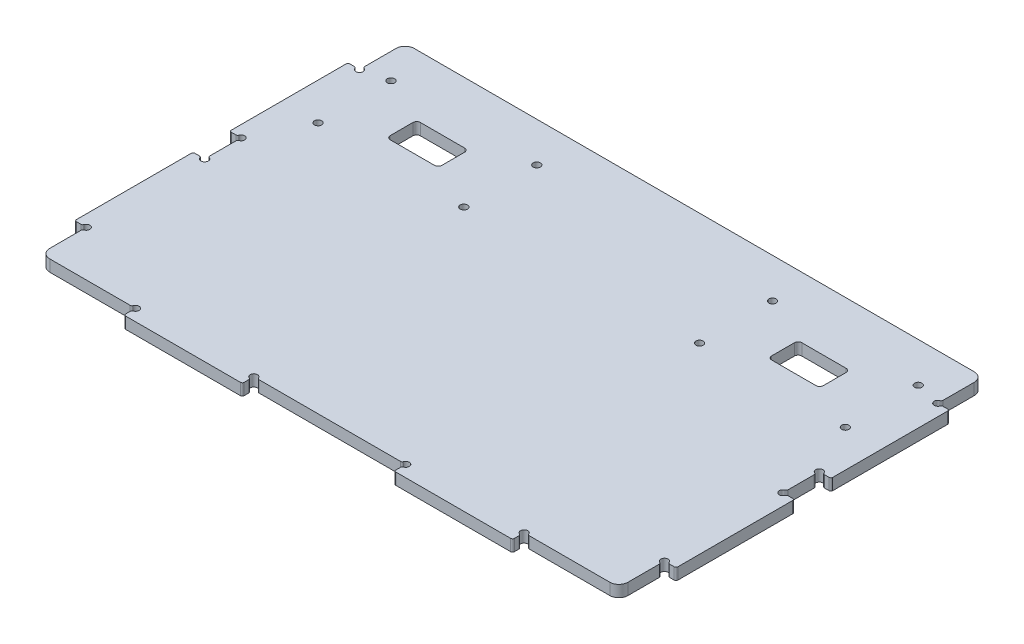
from build123d import *

# Parameters (mm, degrees)
SKETCH1_W              = 317.3
SKETCH1_H              = 363.32
BOSS_EXTRUDE1_DEPTH    = 6.35
SKETCH11_W             = 28.32
SKETCH11_H             = 16.5
CUT_EXTRUDE8_DEPTH     = 7.35
SKETCH12_R             = 2
CUT_EXTRUDE9_DEPTH     = 7.35
FILLET4_R              = 2
SKETCH14_W             = 317.3
SKETCH14_H             = 163.32
CUT_EXTRUDE10_DEPTH    = 6.35
SKETCH15_W             = 6.35
SKETCH15_H             = 65
BOSS_EXTRUDE2_DEPTH    = 6.35
SKETCH16_R             = 2
CUT_EXTRUDE11_DEPTH    = 6.35
FILLET5_R              = 1
LPATTERN1_COUNT        = 2
LPATTERN1_PITCH        = 85
FILLET5_OF_LPATTERN1_R = 1
FILLET6_R              = 5
SKETCH18_W             = 6.35
SKETCH18_H             = 65
BOSS_EXTRUDE3_DEPTH    = 6.35
SKETCH19_R             = 2
CUT_EXTRUDE12_DEPTH    = 6.35
FILLET7_R              = 1
LPATTERN2_COUNT        = 2
LPATTERN2_PITCH        = 85
FILLET7_OF_LPATTERN2_R = 1
SKETCH20_W             = 65
SKETCH20_H             = 6.35
BOSS_EXTRUDE4_DEPTH    = 6.35
SKETCH21_R             = 2
CUT_EXTRUDE13_DEPTH    = 6.35
FILLET8_R              = 1
FILLET8_OF_MIRROR10_R  = 1


with BuildPart() as part:
    # Sketch1 → Boss-Extrude1 (new body)
    with BuildSketch(Plane(origin=(0, 0, 0), x_dir=(1, 0, 0), z_dir=(0, 1, 0))):
        Rectangle(SKETCH1_W, SKETCH1_H)
    extrude(amount=-BOSS_EXTRUDE1_DEPTH)

    # Sketch11 → Cut-Extrude8 (cut, through all)
    with BuildSketch(Plane(origin=(0, 0, 0), x_dir=(1, 0, 0), z_dir=(0, 1, 0))):
        with Locations((104.666666667, -23.41)):
            Rectangle(SKETCH11_W, SKETCH11_H)
    cut_extrude8 = extrude(amount=-CUT_EXTRUDE8_DEPTH, mode=Mode.SUBTRACT)

    # Sketch12 → Cut-Extrude9 (cut, through all)
    with BuildSketch(Plane(origin=(0, 0, 0), x_dir=(1, 0, 0), z_dir=(0, 1, 0))):
        with Locations((64.666666667, -3.41)):
            Circle(SKETCH12_R)
        with Locations((144.666666667, -3.41)):
            Circle(SKETCH12_R)
        with Locations((144.666666667, -43.41)):
            Circle(SKETCH12_R)
        with Locations((64.666666667, -43.41)):
            Circle(SKETCH12_R)
    cut_extrude9 = extrude(amount=-CUT_EXTRUDE9_DEPTH, mode=Mode.SUBTRACT)

    # Mirror3: Cut-Extrude8, Cut-Extrude9 across plane
    add(cut_extrude8.mirror(Plane(origin=(0, 0, 0), x_dir=(0, 0, 1), z_dir=(1, 0, 0))), mode=Mode.SUBTRACT)
    add(cut_extrude9.mirror(Plane(origin=(0, 0, 0), x_dir=(0, 0, 1), z_dir=(1, 0, 0))), mode=Mode.SUBTRACT)

    # Fillet4
    fillet4_edges = [part.edges().sort_by_distance(p)[0] for p in [
        (90.506666667, -3.175, 31.66),
        (90.506666667, -3.175, 15.16),
        (118.826666667, -3.175, 15.16),
        (118.826666667, -3.175, 31.66),
        (-90.506666667, -3.175, 15.16),
        (-90.506666667, -3.175, 31.66),
        (-118.826666667, -3.175, 31.66),
        (-118.826666667, -3.175, 15.16),
    ]]
    fillet(fillet4_edges, radius=FILLET4_R)

    # Sketch14 → Cut-Extrude10 (cut)
    with BuildSketch(Plane(origin=(0, 0, 0), x_dir=(1, 0, 0), z_dir=(0, 1, 0))):
        with Locations((0, 100)):
            Rectangle(SKETCH14_W, SKETCH14_H)
    extrude(amount=-CUT_EXTRUDE10_DEPTH, mode=Mode.SUBTRACT)

    # Sketch15 → Boss-Extrude2 (add)
    with BuildSketch(Plane(origin=(0, 0, 0), x_dir=(1, 0, 0), z_dir=(0, 1, 0))):
        with Locations((161.825, -39.16)):
            Rectangle(SKETCH15_W, SKETCH15_H)
    boss_extrude2 = extrude(amount=-BOSS_EXTRUDE2_DEPTH)

    # Sketch16 → Cut-Extrude11 (cut)
    with BuildSketch(Plane(origin=(0, 0, 0), x_dir=(1, 0, 0), z_dir=(0, 1, 0))):
        with Locations((158.65, -71.66)):
            Circle(SKETCH16_R)
        with Locations((158.65, -6.66)):
            Circle(SKETCH16_R)
    cut_extrude11 = extrude(amount=-CUT_EXTRUDE11_DEPTH, mode=Mode.SUBTRACT)

    # Fillet5
    fillet5_edges = [part.edges().sort_by_distance(p)[0] for p in [
        (165, -3.175, 6.66),
        (165, -3.175, 71.66),
        (160.65, -3.175, 71.66),
        (160.65, -3.175, 6.66),
        (158.65, -3.175, 73.66),
        (158.65, -3.175, 4.66),
    ]]
    fillet(fillet5_edges, radius=FILLET5_R)

    # LPattern1: Boss-Extrude2, Cut-Extrude11 ×2
    with Locations(*[(0, 0, i * LPATTERN1_PITCH) for i in range(1, LPATTERN1_COUNT)]):
        add(boss_extrude2)
        add(cut_extrude11, mode=Mode.SUBTRACT)

    # Fillet5 of LPattern1
    fillet5_of_lpattern1_edges = [part.edges().sort_by_distance(p)[0] for p in [
        (165, -3.175, 91.66),
        (165, -3.175, 156.66),
        (160.65, -3.175, 156.66),
        (160.65, -3.175, 91.66),
        (158.65, -3.175, 158.66),
        (158.65, -3.175, 89.66),
    ]]
    fillet(fillet5_of_lpattern1_edges, radius=FILLET5_OF_LPATTERN1_R)

    # Fillet6
    fillet6_edges = [part.edges().sort_by_distance(p)[0] for p in [
        (158.65, -3.175, -18.34),
        (-158.65, -3.175, -18.34),
        (158.65, -3.175, 181.66),
        (-158.65, -3.175, 181.66),
    ]]
    fillet(fillet6_edges, radius=FILLET6_R)

    # Sketch18 → Boss-Extrude3 (add)
    with BuildSketch(Plane(origin=(0, 0, 0), x_dir=(1, 0, 0), z_dir=(0, 1, 0))):
        with Locations((-161.825, -39.16)):
            Rectangle(SKETCH18_W, SKETCH18_H)
    boss_extrude3 = extrude(amount=-BOSS_EXTRUDE3_DEPTH)

    # Sketch19 → Cut-Extrude12 (cut)
    with BuildSketch(Plane(origin=(0, 0, 0), x_dir=(1, 0, 0), z_dir=(0, 1, 0))):
        with Locations((-158.65, -6.66)):
            Circle(SKETCH19_R)
        with Locations((-158.65, -71.66)):
            Circle(SKETCH19_R)
    cut_extrude12 = extrude(amount=-CUT_EXTRUDE12_DEPTH, mode=Mode.SUBTRACT)

    # Fillet7
    fillet7_edges = [part.edges().sort_by_distance(p)[0] for p in [
        (-165, -3.175, 71.66),
        (-165, -3.175, 6.66),
        (-160.65, -3.175, 6.66),
        (-160.65, -3.175, 71.66),
        (-158.65, -3.175, 4.66),
        (-158.65, -3.175, 73.66),
    ]]
    fillet(fillet7_edges, radius=FILLET7_R)

    # LPattern2: Boss-Extrude3, Cut-Extrude12 ×2
    with Locations(*[(0, 0, i * LPATTERN2_PITCH) for i in range(1, LPATTERN2_COUNT)]):
        add(boss_extrude3)
        add(cut_extrude12, mode=Mode.SUBTRACT)

    # Fillet7 of LPattern2
    fillet7_of_lpattern2_edges = [part.edges().sort_by_distance(p)[0] for p in [
        (-165, -3.175, 156.66),
        (-165, -3.175, 91.66),
        (-160.65, -3.175, 91.66),
        (-160.65, -3.175, 156.66),
        (-158.65, -3.175, 89.66),
        (-158.65, -3.175, 158.66),
    ]]
    fillet(fillet7_of_lpattern2_edges, radius=FILLET7_OF_LPATTERN2_R)

    # Sketch20 → Boss-Extrude4 (add)
    with BuildSketch(Plane(origin=(0, 0, 0), x_dir=(1, 0, 0), z_dir=(0, 1, 0))):
        with Locations((74.15, -184.835)):
            Rectangle(SKETCH20_W, SKETCH20_H)
    boss_extrude4 = extrude(amount=-BOSS_EXTRUDE4_DEPTH)

    # Sketch21 → Cut-Extrude13 (cut)
    with BuildSketch(Plane(origin=(0, 0, 0), x_dir=(1, 0, 0), z_dir=(0, 1, 0))):
        with Locations((41.65, -181.66)):
            Circle(SKETCH21_R)
        with Locations((106.65, -181.66)):
            Circle(SKETCH21_R)
    cut_extrude13 = extrude(amount=-CUT_EXTRUDE13_DEPTH, mode=Mode.SUBTRACT)

    # Fillet8
    fillet8_edges = [part.edges().sort_by_distance(p)[0] for p in [
        (41.65, -3.175, 188.01),
        (106.65, -3.175, 188.01),
        (106.65, -3.175, 183.66),
        (41.65, -3.175, 183.66),
        (39.65, -3.175, 181.66),
        (108.65, -3.175, 181.66),
    ]]
    fillet(fillet8_edges, radius=FILLET8_R)

    # Mirror10: Boss-Extrude4, Cut-Extrude13 across plane
    add(boss_extrude4.mirror(Plane(origin=(0, 0, 0), x_dir=(0, 0, 1), z_dir=(1, 0, 0))))
    add(cut_extrude13.mirror(Plane(origin=(0, 0, 0), x_dir=(0, 0, 1), z_dir=(1, 0, 0))), mode=Mode.SUBTRACT)

    # Fillet8 of Mirror10
    fillet8_of_mirror10_edges = [part.edges().sort_by_distance(p)[0] for p in [
        (-41.65, -3.175, 188.01),
        (-106.65, -3.175, 188.01),
        (-106.65, -3.175, 183.66),
        (-41.65, -3.175, 183.66),
        (-39.65, -3.175, 181.66),
        (-108.65, -3.175, 181.66),
    ]]
    fillet(fillet8_of_mirror10_edges, radius=FILLET8_OF_MIRROR10_R)


solid = part.part
